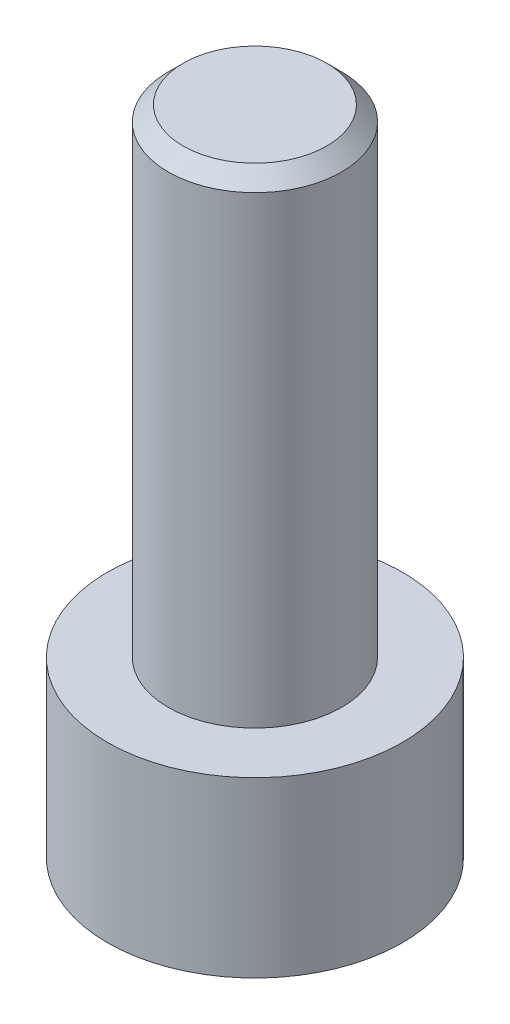
from build123d import *

# Parameters (mm, degrees)
SKETCH1_R           = 2.465
BOSS_EXTRUDE1_DEPTH = 2.9
SKETCH2_R           = 1.45
BOSS_EXTRUDE2_DEPTH = 8
CUT_EXTRUDE1_DEPTH  = 1.9
CHAMFER1_SIZE       = 0.25


with BuildPart() as part:
    # Sketch1 → Boss-Extrude1 (new body)
    with BuildSketch(Plane(origin=(0, 0, 0), x_dir=(1, 0, 0), z_dir=(0, 1, 0))):
        Circle(SKETCH1_R)
    extrude(amount=BOSS_EXTRUDE1_DEPTH)

    # Sketch2 → Boss-Extrude2 (add)
    with BuildSketch(Plane(origin=(0, 2.9, 0), x_dir=(1, 0, 0), z_dir=(0, 1, 0))):
        Circle(SKETCH2_R)
    extrude(amount=BOSS_EXTRUDE2_DEPTH)

    # Sketch3 → Cut-Extrude1 (cut)
    with BuildSketch(Plane.XZ):
        Polygon((0.733234842, -1.27), (1.466469684, 0), (0.733234842, 1.27), (-0.733234842, 1.27), (-1.466469684, 0), (-0.733234842, -1.27), align=None)
    extrude(amount=-CUT_EXTRUDE1_DEPTH, mode=Mode.SUBTRACT)

    # Chamfer1
    chamfer1_edges = [part.edges().sort_by_distance(p)[0] for p in [
        (-1.45, 10.9, 0),
    ]]
    chamfer(chamfer1_edges, length=CHAMFER1_SIZE)


solid = part.part
